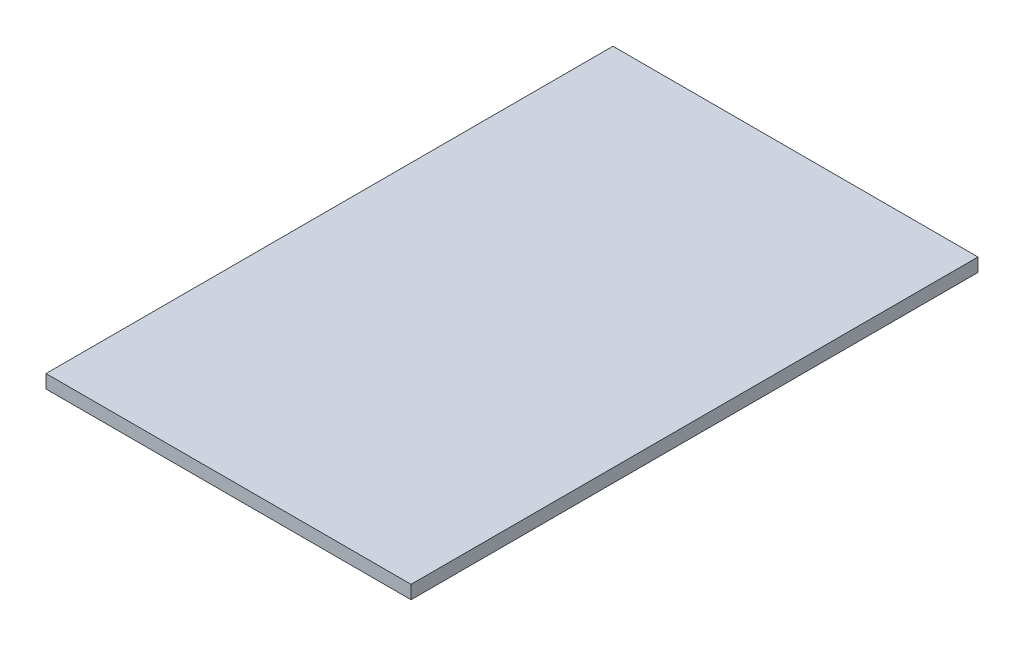
from build123d import *

# Parameters (mm, degrees)
SKETCH_1_W      = 490
SKETCH_1_H      = 761
EXTRUDE_1_DEPTH = 18


with BuildPart() as part:
    # Эскиз1 → Бобышка-Вытянуть1 (new body)
    with BuildSketch(Plane(origin=(0, 0, 0), x_dir=(1, 0, 0), z_dir=(0, 1, 0))):
        Rectangle(SKETCH_1_W, SKETCH_1_H)
    extrude(amount=EXTRUDE_1_DEPTH)


solid = part.part
